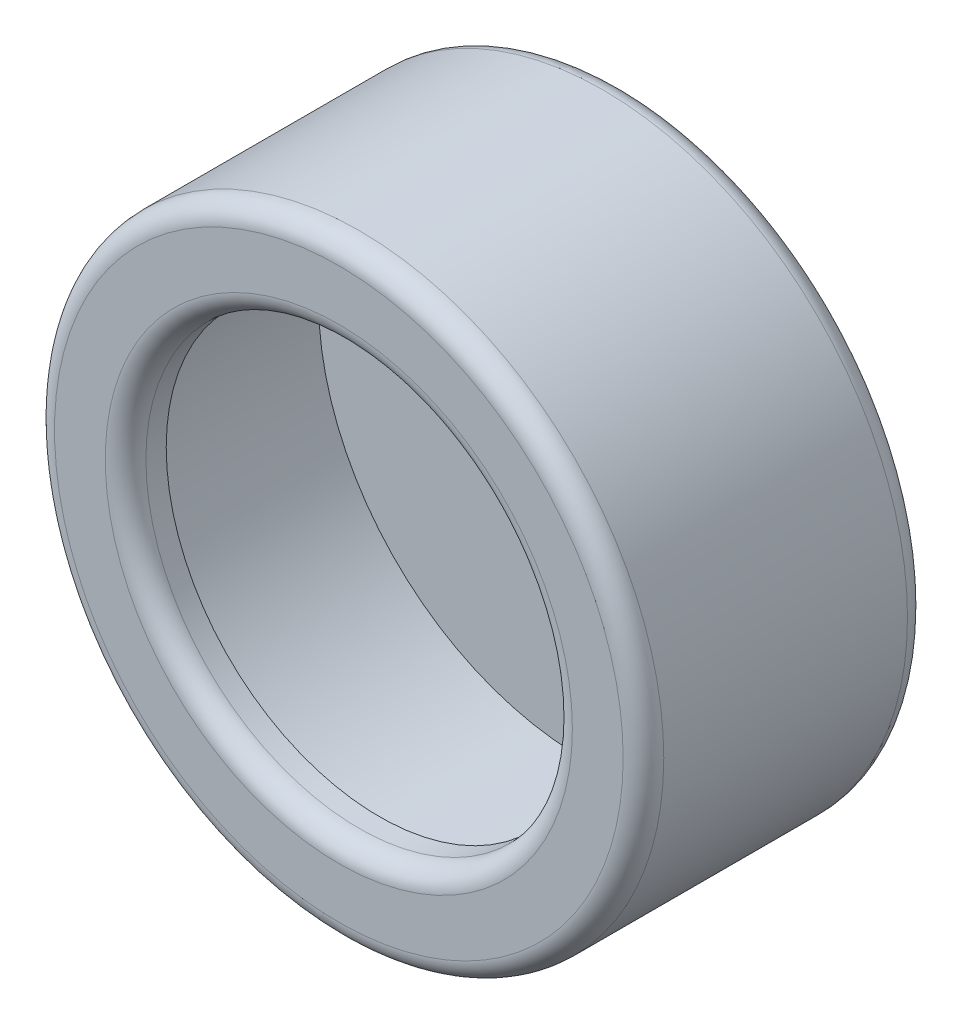
from build123d import *

# Parameters (mm, degrees)
SKETCH_1_R          = 7.5
EXTRUDE_1_DEPTH     = 7
SKETCH_2_R          = 5.25
CUT_EXTRUDE_1_DEPTH = 6
SKETCH_3_R          = 6.5
CUT_EXTRUDE_2_DEPTH = 5
FILLET_1_R          = 0.5


with BuildPart() as part:
    # 草图1 → 凸台-拉伸1 (new body)
    with BuildSketch(Plane.XY):
        Circle(SKETCH_1_R)
    extrude(amount=EXTRUDE_1_DEPTH)

    # 草图2 → 切除-拉伸1 (cut)
    with BuildSketch(Plane.XY.offset(7)):
        Circle(SKETCH_2_R)
    extrude(amount=-CUT_EXTRUDE_1_DEPTH, mode=Mode.SUBTRACT)

    # 草图3 → 切除-拉伸2 (cut)
    with BuildSketch(Plane.XY.offset(1)):
        Circle(SKETCH_3_R)
    extrude(amount=CUT_EXTRUDE_2_DEPTH, mode=Mode.SUBTRACT)

    # 圆角1
    fillet_1_edges = [part.edges().sort_by_distance(p)[0] for p in [
        (-7.5, 0, 0),
        (-7.5, 0, 7),
        (-5.25, 0, 7),
    ]]
    fillet(fillet_1_edges, radius=FILLET_1_R)


solid = part.part
